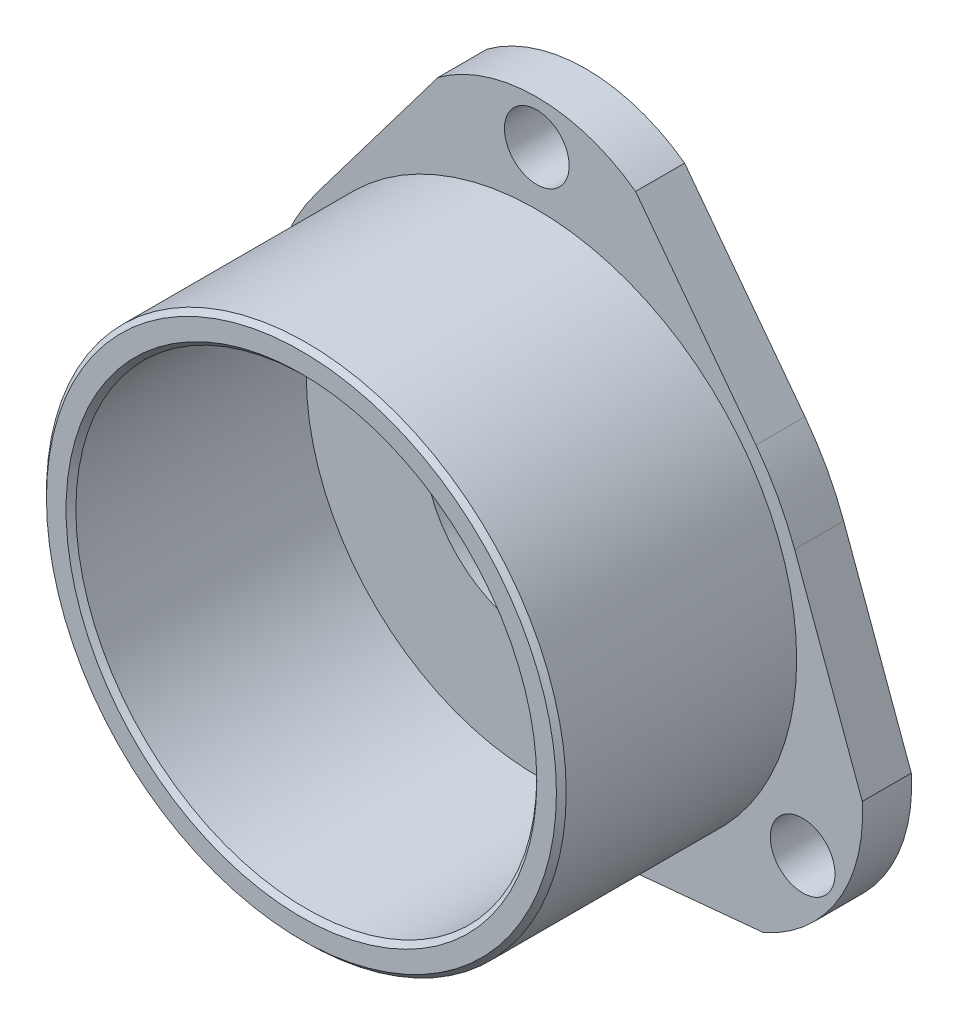
from build123d import *

# Parameters (mm, degrees)
ESTRUSIONE_ESTRUSIONE1_DEPTH   = 5
FORO_PER_VITE_M6_1_D           = 6.6
FORO_PER_VITE_M6_1_CSINK_D     = 6.65
FORO_PER_VITE_M6_1_CSINK_ANGLE = 90
SCHIZZO4_R                     = 26.5
SCHIZZO4_R_2                   = 23.5
ESTRUSIONE_ESTRUSIONE2_DEPTH   = 24
SCHIZZO5_R                     = 11.5
TAGLIO_ESTRUSIONE1_DEPTH       = 5
SMUSSO1_SIZE                   = 0.5


with BuildPart() as part:
    # Schizzo1 → Estrusione-Estrusione1 (new body)
    with BuildSketch(Plane.XY):
        with BuildLine():
            Line((2.4885721, -39.50156014), (20.319683996, -37.803546229))
            ThreePointArc((20.319683996, -37.803546229), (27.963406237, -31.07606674), (30.391301643, -21.187143955))
            Line((30.391301643, -21.187143955), (23.49327463, -2.368382239))
            ThreePointArc((23.49327463, -2.368382239), (21.78857361, 1.396167849), (19.548342312, 4.868804695))
            Line((19.548342312, 4.868804695), (7.275368714, 21.121066322))
            ThreePointArc((7.275368714, 21.121066322), (-2.796248933, 24.425719741), (-12.86786658, 21.121066322))
            Line((-12.86786658, 21.121066322), (-25.140840178, 4.868804695))
            ThreePointArc((-25.140840178, 4.868804695), (-27.381071476, 1.396167849), (-29.085772496, -2.368382239))
            Line((-29.085772496, -2.368382239), (-35.983799509, -21.187143955))
            ThreePointArc((-35.983799509, -21.187143955), (-33.555904103, -31.07606674), (-25.912181862, -37.803546229))
            Line((-25.912181862, -37.803546229), (-8.081069967, -39.50156014))
            ThreePointArc((-8.081069967, -39.50156014), (-2.796248933, -40.00482094), (2.4885721, -39.50156014))
        make_face()
    extrude(amount=ESTRUSIONE_ESTRUSIONE1_DEPTH)

    # Foro per Vite M6-1 (through all)
    with Locations(Plane(origin=(0, 0, 0), x_dir=(-1, 0, 0), z_dir=(0, 0, -1))):
        with Locations((2.796248933, 19.99517906), (29.907132357, -29.00482094), (-24.31463449, -29.00482094)):
            CounterSinkHole(FORO_PER_VITE_M6_1_D / 2, FORO_PER_VITE_M6_1_CSINK_D / 2, counter_sink_angle=FORO_PER_VITE_M6_1_CSINK_ANGLE)

    # Schizzo4 → Estrusione-Estrusione2 (add)
    with BuildSketch(Plane.XY.offset(5)):
        with Locations((-2.796248933, -12.00482094)):
            Circle(SCHIZZO4_R)
        with Locations((-2.796248933, -12.00482094)):
            Circle(SCHIZZO4_R_2, mode=Mode.SUBTRACT)
    extrude(amount=ESTRUSIONE_ESTRUSIONE2_DEPTH)

    # Schizzo5 → Taglio-Estrusione1 (cut)
    with BuildSketch(Plane(origin=(0, 0, 0), x_dir=(-1, 0, 0), z_dir=(0, 0, -1))):
        with Locations((2.796248933, -12.00482094)):
            Circle(SCHIZZO5_R)
    extrude(amount=-TAGLIO_ESTRUSIONE1_DEPTH, mode=Mode.SUBTRACT)

    # Smusso1
    smusso1_edges = [part.edges().sort_by_distance(p)[0] for p in [
        (-29.296248933, -12.00482094, 29),
        (-26.296248933, -12.00482094, 29),
    ]]
    chamfer(smusso1_edges, length=SMUSSO1_SIZE)


solid = part.part
